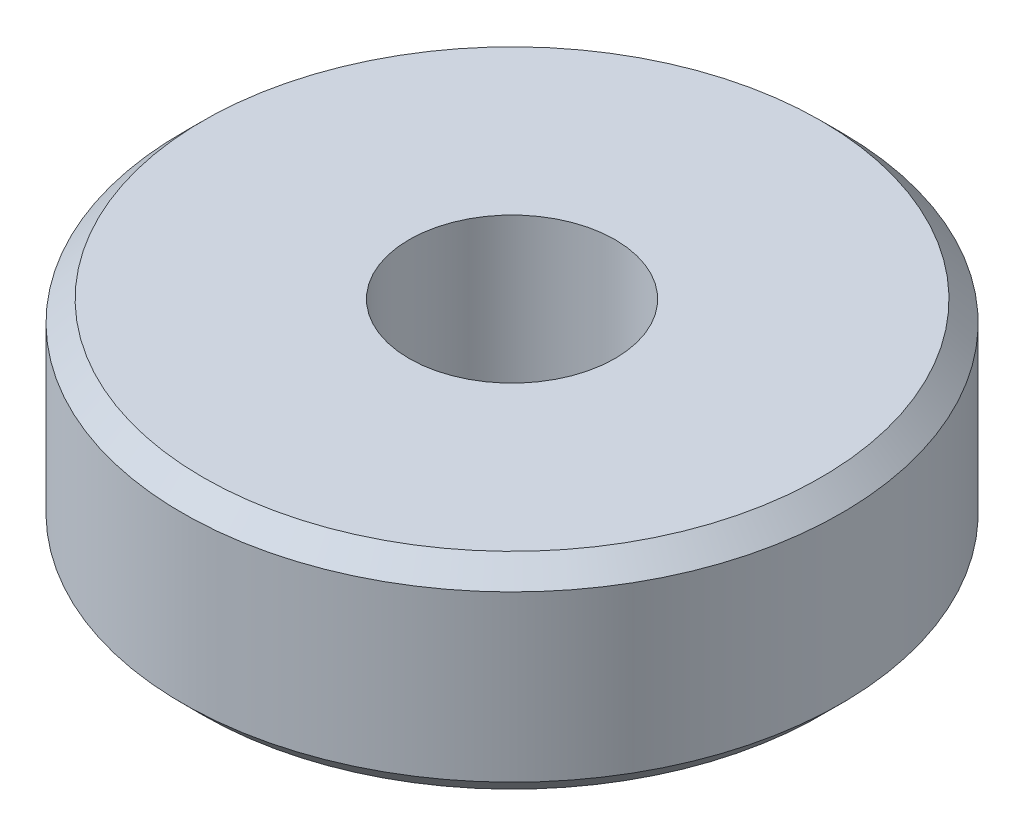
from build123d import *


with BuildPart() as part:
    # Sketch1 → Revolve1 (revolve)
    with BuildSketch(Plane.XY):
        Polygon((7.5, 5), (8, 4.5), (8, 0.5), (7.5, 0), (2.5, 0), (2.5, 5), align=None)
    revolve(axis=Axis((0, 0, 0), (0, 1, 0)))


solid = part.part
